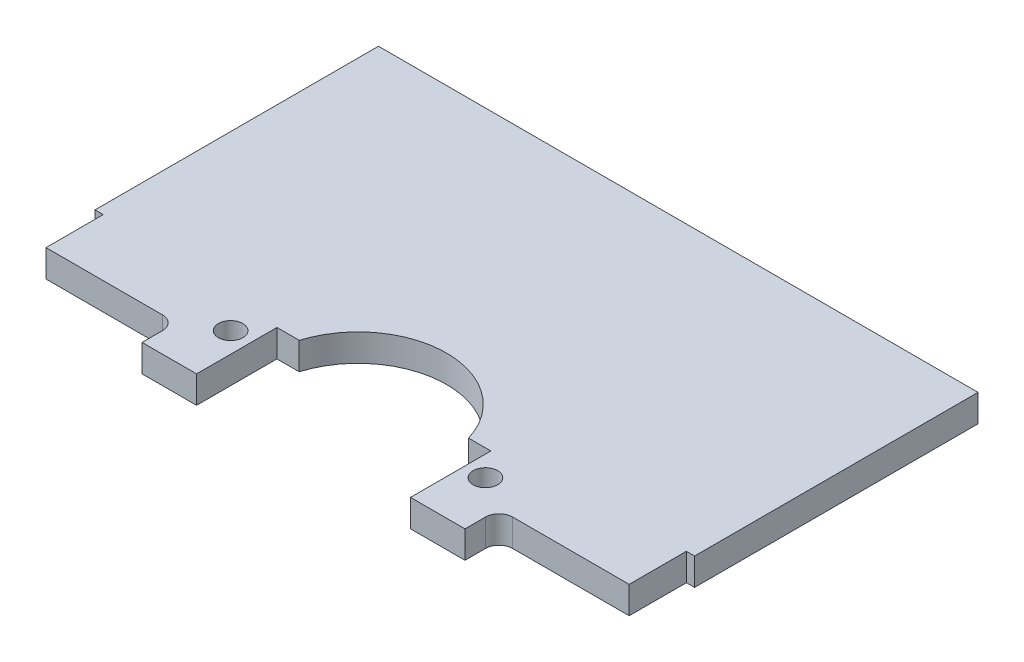
from build123d import *

# Parameters (mm, degrees)
SKETCH1_R           = 1.143
SKETCH1_W           = 5.08
SKETCH1_H           = 3.175
BOSS_EXTRUDE1_DEPTH = 2.54
FILLET1_R           = 1.27


with BuildPart() as part:
    # Sketch1 → Boss-Extrude1 (new body)
    with BuildSketch(Plane(origin=(0, 0, 0), x_dir=(1, 0, 0), z_dir=(0, 1, 0))):
        with BuildLine():
            Line((-27.94, 13.208), (-27.94, -13.208))
            Line((-27.94, -13.208), (-27.178, -13.208))
            Line((-27.178, -13.208), (-7.509126714, -13.208))
            ThreePointArc((-7.509126714, -13.208), (0, -8.382), (7.509126714, -13.208))
            Line((7.509126714, -13.208), (27.178, -13.208))
            Line((27.178, -13.208), (27.94, -13.208))
            Line((27.94, -13.208), (27.94, 13.208))
            Line((27.94, 13.208), (-27.94, 13.208))
        make_face()
        with BuildLine():
            Line((-7.509126714, -13.208), (-27.178, -13.208))
            Line((-27.178, -13.208), (-27.178, -18.542))
            Line((-27.178, -18.542), (-15.0495, -18.542))
            Line((-15.0495, -18.542), (-9.9695, -18.542))
            Line((-9.9695, -18.542), (-9.9695, -14.224))
            Line((-9.9695, -14.224), (-7.894457296, -14.224))
            ThreePointArc((-7.894457296, -14.224), (-7.718527326, -13.709652922), (-7.509126714, -13.208))
        make_face()
        with Locations((-11.8745, -16.637)):
            Circle(SKETCH1_R, mode=Mode.SUBTRACT)
        with BuildLine():
            Line((27.178, -13.208), (7.509126714, -13.208))
            ThreePointArc((7.509126714, -13.208), (7.718527326, -13.709652922), (7.894457296, -14.224))
            Line((7.894457296, -14.224), (9.9695, -14.224))
            Line((9.9695, -14.224), (9.9695, -18.542))
            Line((9.9695, -18.542), (15.0495, -18.542))
            Line((15.0495, -18.542), (27.178, -18.542))
            Line((27.178, -18.542), (27.178, -13.208))
        make_face()
        with Locations((11.8745, -16.637)):
            Circle(SKETCH1_R, mode=Mode.SUBTRACT)
        with Locations((-12.5095, -20.1295)):
            Rectangle(SKETCH1_W, SKETCH1_H)
        with Locations((12.5095, -20.1295)):
            Rectangle(SKETCH1_W, SKETCH1_H)
    extrude(amount=BOSS_EXTRUDE1_DEPTH)

    # Fillet1
    fillet1_edges = [part.edges().sort_by_distance(p)[0] for p in [
        (15.0495, 1.27, 18.542),
        (-15.0495, 1.27, 18.542),
    ]]
    fillet(fillet1_edges, radius=FILLET1_R)


solid = part.part
